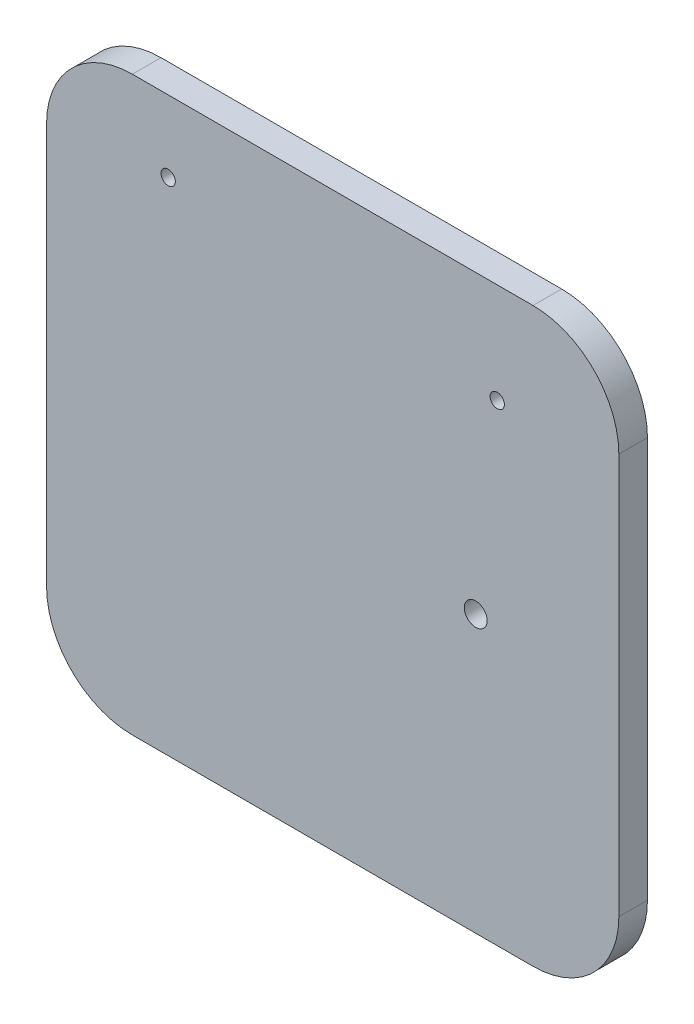
from build123d import *

# Parameters (mm, degrees)
SKETCH1_R               = 4
BOSS_EXTRUDE1_DEPTH     = 10
SKETCH2_R               = 2.5
CUT_EXTRUDE1_DEPTH      = 1
CUT_EXTRUDE1_DEPTH_BACK = 10


with BuildPart() as part:
    # Sketch1 → Boss-Extrude1 (new body)
    with BuildSketch(Plane.XY):
        with BuildLine():
            Line((-70, -100), (70, -100))
            ThreePointArc((70, -100), (91.213203436, -91.213203436), (100, -70))
            Line((100, -70), (100, 70))
            ThreePointArc((100, 70), (91.213203436, 91.213203436), (70, 100))
            Line((70, 100), (-70, 100))
            ThreePointArc((-70, 100), (-91.213203436, 91.213203436), (-100, 70))
            Line((-100, 70), (-100, -70))
            ThreePointArc((-100, -70), (-91.213203436, -91.213203436), (-70, -100))
        make_face()
        with Locations((49.983002612, -3.429415932)):
            Circle(SKETCH1_R, mode=Mode.SUBTRACT)
    extrude(amount=BOSS_EXTRUDE1_DEPTH)

    # Sketch2 → Cut-Extrude1 (cut, two sides)
    with BuildSketch(Plane.XY.offset(10)) as cut_extrude1_sk:
        with Locations((-57.5, 75)):
            Circle(SKETCH2_R)
        with Locations((57.5, 65)):
            Circle(SKETCH2_R)
    extrude(amount=CUT_EXTRUDE1_DEPTH, mode=Mode.SUBTRACT)
    extrude(cut_extrude1_sk.sketch, amount=-CUT_EXTRUDE1_DEPTH_BACK, mode=Mode.SUBTRACT)


solid = part.part
